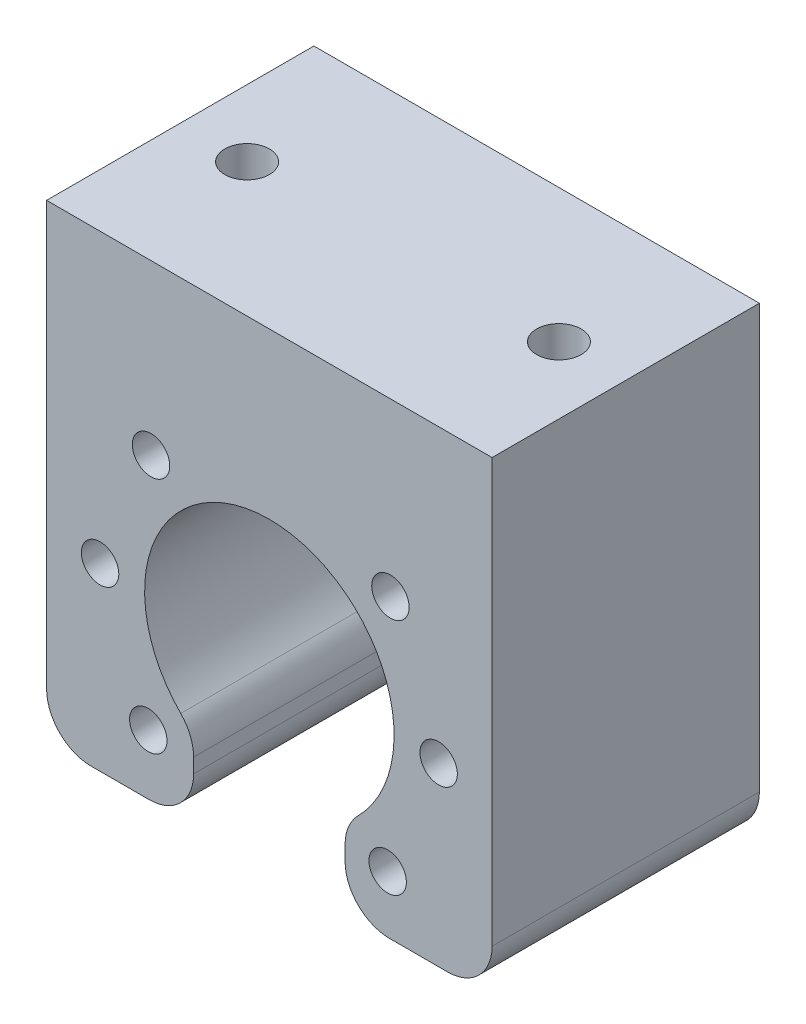
from build123d import *

# Parameters (mm, degrees)
EXTRUDE1_DEPTH        = 30
FILLET1_R             = 5
M5_TAPPED_HOLE1_D     = 4.2
M6_TAPPED_HOLE1_D     = 5
M6_TAPPED_HOLE1_DEPTH = 20
M6_TAPPED_HOLE1_TIP   = 1.502151548


with BuildPart() as part:
    # Sketch1 → Extrude1 (new body)
    with BuildSketch(Plane.XY):
        with BuildLine():
            Line((-25, 32.5), (25, 32.5))
            Line((25, 32.5), (25, -20))
            Line((25, -20), (8.5, -20))
            Line((8.5, -20), (8.5, -11.124297731))
            ThreePointArc((8.5, -11.124297731), (0, 14), (-8.5, -11.124297731))
            Line((-8.5, -11.124297731), (-8.5, -20))
            Line((-8.5, -20), (-25, -20))
            Line((-25, -20), (-25, 32.5))
        make_face()
    extrude(amount=EXTRUDE1_DEPTH)

    # Fillet1
    fillet1_edges = [part.edges().sort_by_distance(p)[0] for p in [
        (-8.5, -20, 15),
        (-25, -20, 15),
        (25, -20, 15),
        (8.5, -20, 15),
        (8.5, -11.124297731, 15),
        (-8.5, -11.124297731, 15),
    ]]
    fillet(fillet1_edges, radius=FILLET1_R)

    # M5 Tapped Hole1 (through all)
    with Locations(Plane(origin=(0, 0, 0), x_dir=(-1, 0, 0), z_dir=(0, 0, -1))):
        with Locations((-13.588507986, 13.279776004), (13.279776004, 13.588507986), (18.998745808, 0.218306478), (13.588507986, -13.279776004), (-13.279776004, -13.588507986), (-18.998745808, -0.218306478)):
            Hole(M5_TAPPED_HOLE1_D / 2)

    # M6 Tapped Hole1
    with Locations(Plane(origin=(0, 32.5, 0), x_dir=(1, 0, 0), z_dir=(0, 1, 0))):
        with Locations((-17.5, -15), (17.5, -15)):
            Hole(M6_TAPPED_HOLE1_D / 2, depth=M6_TAPPED_HOLE1_DEPTH)
            with Locations((0, 0, -(M6_TAPPED_HOLE1_DEPTH + M6_TAPPED_HOLE1_TIP / 2))):  # 118° drill point
                Cone(0, M6_TAPPED_HOLE1_D / 2, M6_TAPPED_HOLE1_TIP, mode=Mode.SUBTRACT)


solid = part.part
